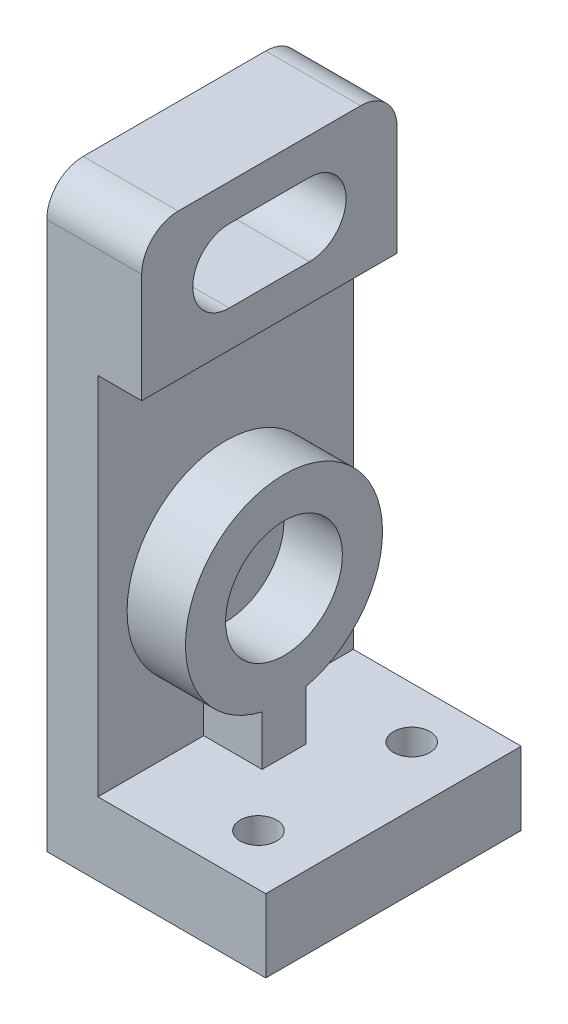
from build123d import *

# Parameters (mm, degrees)
IZIM1_W                     = 30
IZIM1_H                     = 35
Y_KSEKLIK_EKSTR_ZYON1_DEPTH = 10
IZIM2_W                     = 7
IZIM2_H                     = 35
Y_KSEKLIK_EKSTR_ZYON2_DEPTH = 70
IZIM3_W                     = 35
IZIM3_H                     = 20
Y_KSEKLIK_EKSTR_ZYON3_DEPTH = 6
RADYUS1_R                   = 5
KES_EKSTR_ZYON1_DEPTH       = 14
IZIM5_R                     = 2.5
KES_EKSTR_ZYON2_DEPTH       = 11
IZIM6_R                     = 8
Y_KSEKLIK_EKSTR_ZYON4_DEPTH = 8


with BuildPart() as part:
    # Çizim1 → Yükseklik-Ekstrüzyon1 (new body)
    with BuildSketch(Plane(origin=(0, 0, 0), x_dir=(1, 0, 0), z_dir=(0, 1, 0))):
        Rectangle(IZIM1_W, IZIM1_H)
    extrude(amount=Y_KSEKLIK_EKSTR_ZYON1_DEPTH)

    # Çizim2 → Yükseklik-Ekstrüzyon2 (add)
    with BuildSketch(Plane(origin=(0, 10, 0), x_dir=(1, 0, 0), z_dir=(0, 1, 0))):
        with Locations((-11.5, 0)):
            Rectangle(IZIM2_W, IZIM2_H)
    extrude(amount=Y_KSEKLIK_EKSTR_ZYON2_DEPTH)

    # Çizim3 → Yükseklik-Ekstrüzyon3 (add)
    with BuildSketch(Plane(origin=(-8, 0, 0), x_dir=(0, 0, -1), z_dir=(1, 0, 0))):
        with Locations((0, 70)):
            Rectangle(IZIM3_W, IZIM3_H)
    extrude(amount=Y_KSEKLIK_EKSTR_ZYON3_DEPTH)

    # Radyus1
    radyus1_edges = [part.edges().sort_by_distance(p)[0] for p in [
        (-8.5, 80, 17.5),
        (-8.5, 80, -17.5),
    ]]
    fillet(radyus1_edges, radius=RADYUS1_R)

    # Çizim4 → Kes-Ekstrüzyon1 (cut, through all)
    with BuildSketch(Plane(origin=(-2, 0, 0), x_dir=(0, 0, -1), z_dir=(1, 0, 0))):
        with BuildLine():
            Line((-5.5, 75), (5.5, 75))
            ThreePointArc((5.5, 75), (10.5, 70), (5.5, 65))
            Line((5.5, 65), (-5.5, 65))
            ThreePointArc((-5.5, 65), (-10.5, 70), (-5.5, 75))
        make_face()
    extrude(amount=-KES_EKSTR_ZYON1_DEPTH, mode=Mode.SUBTRACT)

    # Çizim5 → Kes-Ekstrüzyon2 (cut, through all)
    with BuildSketch(Plane(origin=(0, 10, 0), x_dir=(1, 0, 0), z_dir=(0, 1, 0))):
        with Locations((7, 10.5)):
            Circle(IZIM5_R)
        with Locations((7, -10.5)):
            Circle(IZIM5_R)
    extrude(amount=-KES_EKSTR_ZYON2_DEPTH, mode=Mode.SUBTRACT)

    # Çizim6 → Yükseklik-Ekstrüzyon4 (add)
    with BuildSketch(Plane(origin=(-8, 0, 0), x_dir=(0, 0, -1), z_dir=(1, 0, 0))):
        with BuildLine():
            Line((-3, 10), (3, 10))
            Line((3, 10), (3, 16.837553419))
            ThreePointArc((3, 16.837553419), (0, 43.5), (-3, 16.837553419))
            Line((-3, 16.837553419), (-3, 10))
        make_face()
        with Locations((0, 30)):
            Circle(IZIM6_R, mode=Mode.SUBTRACT)
    extrude(amount=Y_KSEKLIK_EKSTR_ZYON4_DEPTH)


solid = part.part
